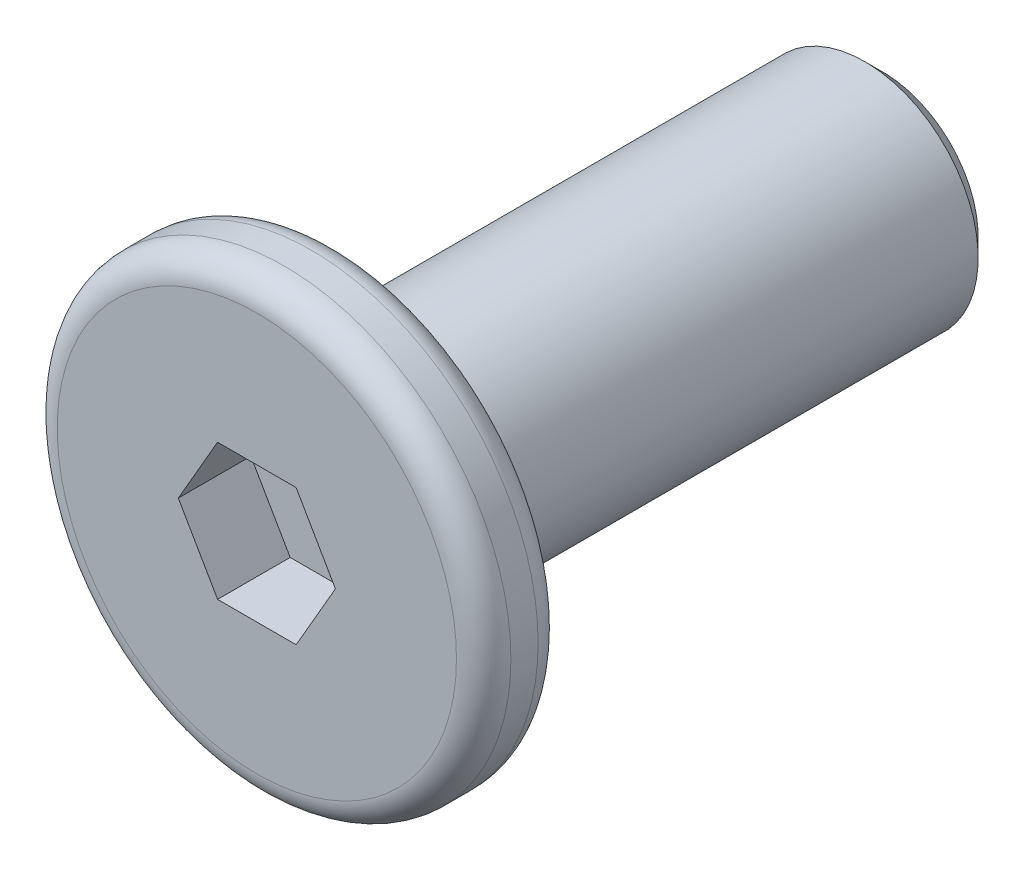
from build123d import *

# Parameters (mm, degrees)
SKETCH_1_R          = 2.5
EXTRUDE_1_DEPTH     = 0.45
SKETCH_2_R          = 1.25
EXTRUDE_2_DEPTH     = 6
CHAMFER_1_SIZE      = 0.2
CUT_EXTRUDE_1_DEPTH = 0.8
FILLET_2_R          = 0.3


with BuildPart() as part:
    # 草图1 → 凸台-拉伸1 (new body, symmetric)
    with BuildSketch(Plane.XY):
        Circle(SKETCH_1_R)
    extrude(amount=EXTRUDE_1_DEPTH, both=True)

    # 草图2 → 凸台-拉伸2 (add)
    with BuildSketch(Plane(origin=(0, 0, -0.45), x_dir=(-1, 0, 0), z_dir=(0, 0, -1))):
        Circle(SKETCH_2_R)
    extrude(amount=EXTRUDE_2_DEPTH)

    # 倒角1
    chamfer_1_edges = [part.edges().sort_by_distance(p)[0] for p in [
        (1.25, 0, -6.45),
    ]]
    chamfer(chamfer_1_edges, length=CHAMFER_1_SIZE)

    # 草图3 → 切除-拉伸1 (cut)
    with BuildSketch(Plane.XY.offset(0.45)):
        Polygon((0.866025404, 0), (0.433012702, 0.75), (-0.433012702, 0.75), (-0.866025404, 0), (-0.433012702, -0.75), (0.433012702, -0.75), align=None)
    extrude(amount=-CUT_EXTRUDE_1_DEPTH, mode=Mode.SUBTRACT)

    # 圆角2
    fillet_2_edges = [part.edges().sort_by_distance(p)[0] for p in [
        (-2.5, 0, -0.45),
        (-2.5, 0, 0.45),
    ]]
    fillet(fillet_2_edges, radius=FILLET_2_R)


solid = part.part
